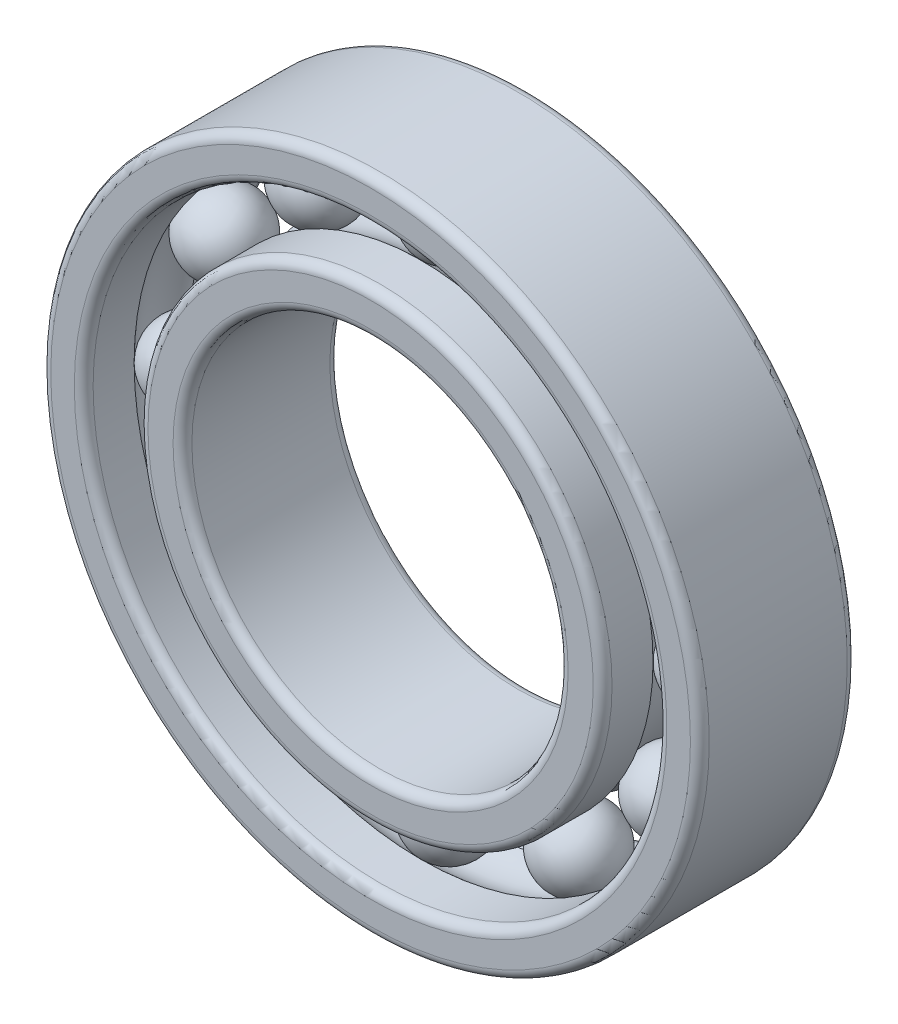
from build123d import *

# Parameters (mm, degrees)
KREISMUSTER4_COUNT = 12
VERRUNDUNG1_R      = 0.3
VERRUNDUNG2_R      = 0.3


with BuildPart() as part:
    # Skizze1 → Rotation1 (revolve)
    with BuildSketch(Plane(origin=(0, 0, 0), x_dir=(0, 0, -1), z_dir=(1, 0, 0))):
        with BuildLine():
            Line((2.5, 10.5), (-2.5, 10.5))
            Line((-2.5, 10.5), (-2.5, 9.15))
            Line((-2.5, 9.15), (-0.892678554, 9.15))
            ThreePointArc((-0.892678554, 9.15), (0, 9.525), (0.892678554, 9.15))
            Line((0.892678554, 9.15), (2.5, 9.15))
            Line((2.5, 9.15), (2.5, 10.5))
        make_face()
        with BuildLine():
            ThreePointArc((0.892678554, 7.4), (0, 7.025), (-0.892678554, 7.4))
            Line((-0.892678554, 7.4), (-2.5, 7.4))
            Line((-2.5, 7.4), (-2.5, 6))
            Line((-2.5, 6), (2.5, 6))
            Line((2.5, 6), (2.5, 7.4))
            Line((2.5, 7.4), (0.892678554, 7.4))
        make_face()
    revolve(axis=Axis((0, 0, 0), (0, 0, -1)))

    # Verrundung1
    verrundung1_edges = [part.edges().sort_by_distance(p)[0] for p in [
        (0, -9.15, -2.5),
        (0, -9.15, 2.5),
        (0, -10.5, -2.5),
        (0, -10.5, 2.5),
    ]]
    fillet(verrundung1_edges, radius=VERRUNDUNG1_R)

    # Verrundung2
    verrundung2_edges = [part.edges().sort_by_distance(p)[0] for p in [
        (0, -7.4, -2.5),
        (0, -6, -2.5),
        (0, -7.4, 2.5),
        (0, -6, 2.5),
    ]]
    fillet(verrundung2_edges, radius=VERRUNDUNG2_R)


with BuildPart() as body_2:
    # Skizze1_5 → Rotation3 (revolve)
    with BuildSketch(Plane(origin=(0, 0, 0), x_dir=(0, 0, -1), z_dir=(1, 0, 0))):
        with BuildLine():
            ThreePointArc((0.892678554, 9.15), (0, 9.525), (-0.892678554, 9.15))
            ThreePointArc((-0.892678554, 9.15), (-1.157226899, 8.747573702), (-1.25, 8.275))
            Line((-1.25, 8.275), (1.25, 8.275))
            ThreePointArc((1.25, 8.275), (1.157226899, 8.747573702), (0.892678554, 9.15))
        make_face()
    revolve(axis=Axis((0, 8.275, 1.25), (0, 0, -1)))


with BuildPart() as kreismuster4_1:
    # Kreismuster4: pattern copy
    add(body_2.part.rotate(Axis((0, 0, -2.5), (0, 0, 1)), 1 * 360 / KREISMUSTER4_COUNT))


with BuildPart() as kreismuster4_2:
    # Kreismuster4: pattern copy
    add(body_2.part.rotate(Axis((0, 0, -2.5), (0, 0, 1)), 2 * 360 / KREISMUSTER4_COUNT))


with BuildPart() as kreismuster4_3:
    # Kreismuster4: pattern copy
    add(body_2.part.rotate(Axis((0, 0, -2.5), (0, 0, 1)), 3 * 360 / KREISMUSTER4_COUNT))


with BuildPart() as kreismuster4_4:
    # Kreismuster4: pattern copy
    add(body_2.part.rotate(Axis((0, 0, -2.5), (0, 0, 1)), 4 * 360 / KREISMUSTER4_COUNT))


with BuildPart() as kreismuster4_5:
    # Kreismuster4: pattern copy
    add(body_2.part.rotate(Axis((0, 0, -2.5), (0, 0, 1)), 5 * 360 / KREISMUSTER4_COUNT))


with BuildPart() as kreismuster4_6:
    # Kreismuster4: pattern copy
    add(body_2.part.rotate(Axis((0, 0, -2.5), (0, 0, 1)), 6 * 360 / KREISMUSTER4_COUNT))


with BuildPart() as kreismuster4_7:
    # Kreismuster4: pattern copy
    add(body_2.part.rotate(Axis((0, 0, -2.5), (0, 0, 1)), 7 * 360 / KREISMUSTER4_COUNT))


with BuildPart() as kreismuster4_8:
    # Kreismuster4: pattern copy
    add(body_2.part.rotate(Axis((0, 0, -2.5), (0, 0, 1)), 8 * 360 / KREISMUSTER4_COUNT))


with BuildPart() as kreismuster4_9:
    # Kreismuster4: pattern copy
    add(body_2.part.rotate(Axis((0, 0, -2.5), (0, 0, 1)), 9 * 360 / KREISMUSTER4_COUNT))


with BuildPart() as kreismuster4_10:
    # Kreismuster4: pattern copy
    add(body_2.part.rotate(Axis((0, 0, -2.5), (0, 0, 1)), 10 * 360 / KREISMUSTER4_COUNT))


with BuildPart() as kreismuster4_11:
    # Kreismuster4: pattern copy
    add(body_2.part.rotate(Axis((0, 0, -2.5), (0, 0, 1)), 11 * 360 / KREISMUSTER4_COUNT))


solid = Compound([part.part, body_2.part, kreismuster4_1.part, kreismuster4_2.part, kreismuster4_3.part, kreismuster4_4.part, kreismuster4_5.part, kreismuster4_6.part, kreismuster4_7.part, kreismuster4_8.part, kreismuster4_9.part, kreismuster4_10.part, kreismuster4_11.part])
